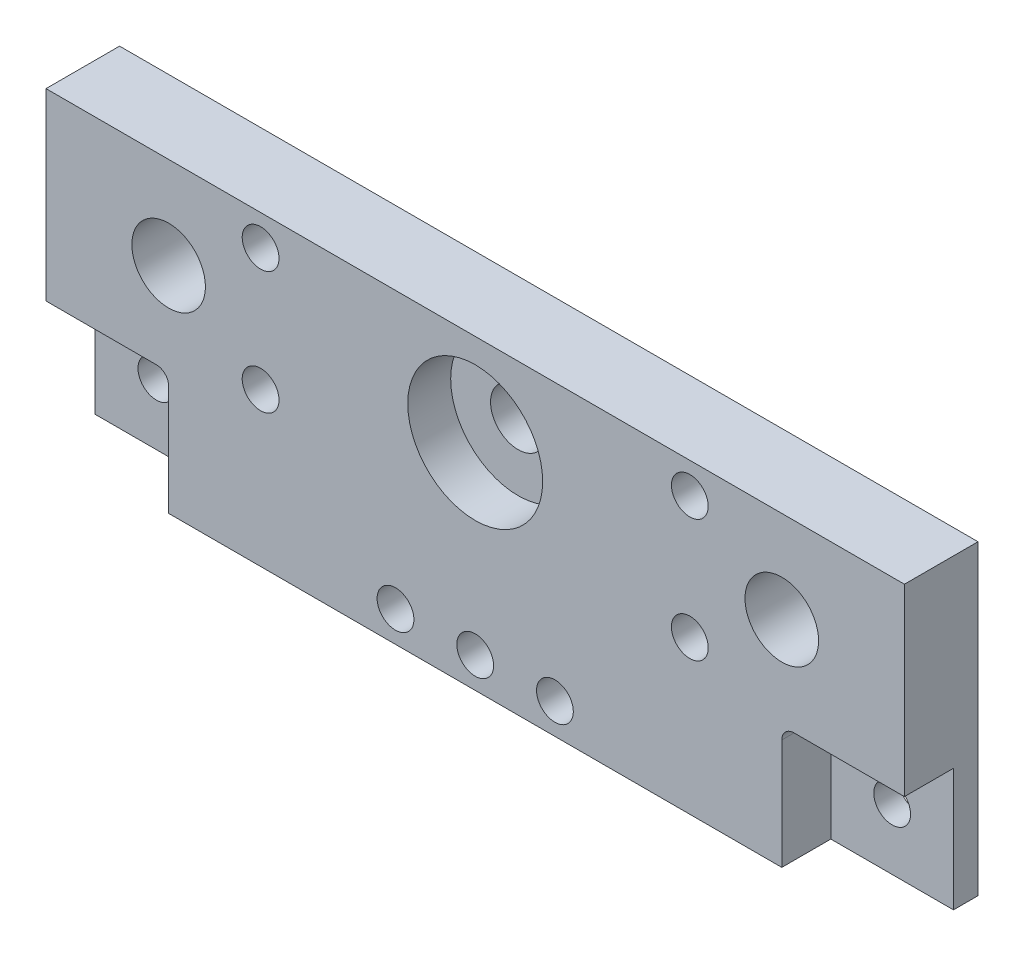
from build123d import *

# Parameters (mm, degrees)
ESQUISSE1_W             = 140
ESQUISSE1_H             = 30
ESQUISSE1_R             = 11
ESQUISSE1_R_2           = 6
ESQUISSE1_R_3           = 3
EXTRUSION1_DEPTH        = 8
ESQUISSE2_W             = 140
ESQUISSE2_H             = 50
BOSS_EXTRU_1_DEPTH      = 4
ESQUISSE3_R             = 3
ENL_V_MAT_EXTRU_1_DEPTH = 5
ESQUISSE4_R             = 11
ESQUISSE4_R_2           = 3
ENL_V_MAT_EXTRU_2_DEPTH = 5
ESQUISSE5_W             = 100
ESQUISSE5_H             = 20
BOSS_EXTRU_2_DEPTH      = 8
ESQUISSE6_R             = 3
ENL_V_MAT_EXTRU_3_DEPTH = 8
ESQUISSE7_R             = 11
BOSS_EXTRU_3_DEPTH      = 5
ESQUISSE8_R             = 4.5
ENL_V_MAT_EXTRU_4_DEPTH = 6
ESQUISSE9_R             = 6
ENL_V_MAT_EXTRU_5_DEPTH = 2
ESQUISSE10_R            = 3
ENL_V_MAT_EXTRU_6_DEPTH = 13
CONG_1_R                = 2
CONG_2_R                = 2


with BuildPart() as part:
    # Esquisse1 → Extrusion1 (new body)
    with BuildSketch(Plane.XY):
        with Locations((49.95634141, -28.081325038)):
            Rectangle(ESQUISSE1_W, ESQUISSE1_H)
        with Locations((49.95634141, -28.081325038)):
            Circle(ESQUISSE1_R, mode=Mode.SUBTRACT)
        with Locations((-0.04365859, -28.081325038)):
            Circle(ESQUISSE1_R_2, mode=Mode.SUBTRACT)
        with Locations((99.95634141, -28.081325038)):
            Circle(ESQUISSE1_R_2, mode=Mode.SUBTRACT)
        with Locations((14.95634141, -18.081325038)):
            Circle(ESQUISSE1_R_3, mode=Mode.SUBTRACT)
        with Locations((14.95634141, -38.081325038)):
            Circle(ESQUISSE1_R_3, mode=Mode.SUBTRACT)
        with Locations((84.95634141, -18.081325038)):
            Circle(ESQUISSE1_R_3, mode=Mode.SUBTRACT)
        with Locations((84.95634141, -38.081325038)):
            Circle(ESQUISSE1_R_3, mode=Mode.SUBTRACT)
    extrude(amount=EXTRUSION1_DEPTH)

    # Esquisse2 → Boss.-Extru.1 (add)
    with BuildSketch(Plane(origin=(0, 0, 0), x_dir=(-1, 0, 0), z_dir=(0, 0, -1))):
        with Locations((-49.95634141, -38.081325038)):
            Rectangle(ESQUISSE2_W, ESQUISSE2_H)
    extrude(amount=BOSS_EXTRU_1_DEPTH)

    # Esquisse3 → Enlèv. mat.-Extru.1 (cut, through all)
    with BuildSketch(Plane.XY):
        with Locations((-10.04365859, -53.081325038)):
            Circle(ESQUISSE3_R)
        with Locations((109.95634141, -53.081325038)):
            Circle(ESQUISSE3_R)
    extrude(amount=-ENL_V_MAT_EXTRU_1_DEPTH, mode=Mode.SUBTRACT)

    # Esquisse4 → Enlèv. mat.-Extru.2 (cut, through all)
    with BuildSketch(Plane.XY):
        with Locations((49.95634141, -28.081325038)):
            Circle(ESQUISSE4_R)
        with Locations((14.95634141, -18.081325038)):
            Circle(ESQUISSE4_R_2)
        with Locations((14.95634141, -38.081325038)):
            Circle(ESQUISSE4_R_2)
        with Locations((84.95634141, -18.081325038)):
            Circle(ESQUISSE4_R_2)
        with Locations((84.95634141, -38.081325038)):
            Circle(ESQUISSE4_R_2)
    extrude(amount=-ENL_V_MAT_EXTRU_2_DEPTH, mode=Mode.SUBTRACT)

    # Esquisse5 → Boss.-Extru.2 (add)
    with BuildSketch(Plane.XY):
        with Locations((49.95634141, -53.081325038)):
            Rectangle(ESQUISSE5_W, ESQUISSE5_H)
    extrude(amount=BOSS_EXTRU_2_DEPTH)

    # Esquisse6 → Enlèv. mat.-Extru.3 (cut)
    with BuildSketch(Plane.XY.offset(8)):
        with Locations((62.95634141, -58.081325038)):
            Circle(ESQUISSE6_R)
        with Locations((36.95634141, -58.081325038)):
            Circle(ESQUISSE6_R)
    extrude(amount=-ENL_V_MAT_EXTRU_3_DEPTH, mode=Mode.SUBTRACT)

    # Esquisse7 → Boss.-Extru.3 (add)
    with BuildSketch(Plane(origin=(0, 0, -4), x_dir=(-1, 0, 0), z_dir=(0, 0, -1))):
        with Locations((-49.95634141, -28.081325038)):
            Circle(ESQUISSE7_R)
    extrude(amount=-BOSS_EXTRU_3_DEPTH)

    # Esquisse8 → Enlèv. mat.-Extru.4 (cut, through all)
    with BuildSketch(Plane.XY.offset(1)):
        with Locations((49.95634141, -28.081325038)):
            Circle(ESQUISSE8_R)
    extrude(amount=-ENL_V_MAT_EXTRU_4_DEPTH, mode=Mode.SUBTRACT)

    # Esquisse9 → Enlèv. mat.-Extru.5 (cut)
    with BuildSketch(Plane.XY):
        with Locations((-0.04365859, -28.081325038)):
            Circle(ESQUISSE9_R)
        with Locations((99.95634141, -28.081325038)):
            Circle(ESQUISSE9_R)
    extrude(amount=-ENL_V_MAT_EXTRU_5_DEPTH, mode=Mode.SUBTRACT)

    # Esquisse10 → Enlèv. mat.-Extru.6 (cut, through all)
    with BuildSketch(Plane.XY.offset(8)):
        with Locations((49.95634141, -58.081325038)):
            Circle(ESQUISSE10_R)
    extrude(amount=-ENL_V_MAT_EXTRU_6_DEPTH, mode=Mode.SUBTRACT)

    # Congé1
    cong_1_edges = [part.edges().sort_by_distance(p)[0] for p in [
        (-0.04365859, -43.081325038, 4),
    ]]
    fillet(cong_1_edges, radius=CONG_1_R)

    # Congé2
    cong_2_edges = [part.edges().sort_by_distance(p)[0] for p in [
        (99.95634141, -43.081325038, 4),
    ]]
    fillet(cong_2_edges, radius=CONG_2_R)


solid = part.part
